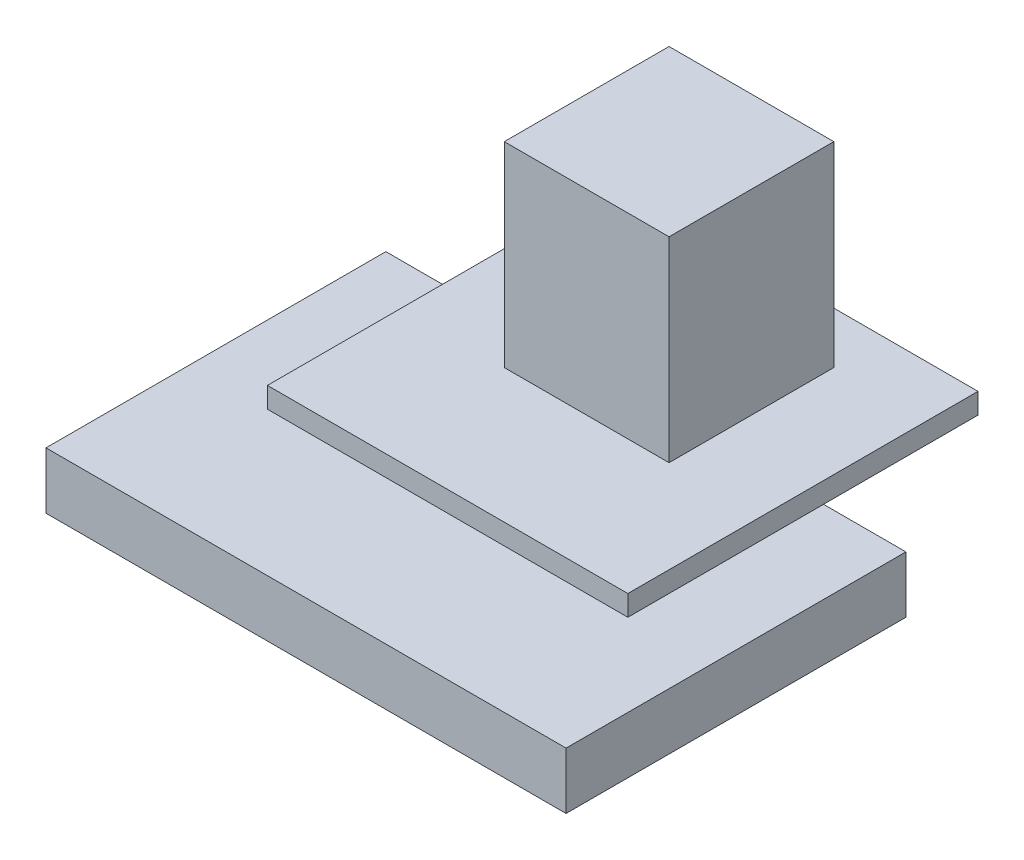
from build123d import *

# Parameters (mm, degrees)
SKETCH1_W           = 50.5
SKETCH1_H           = 33
BOSS_EXTRUDE1_DEPTH = 5.5
SKETCH2_W           = 35
SKETCH2_H           = 34
BOSS_EXTRUDE2_DEPTH = 2
SKETCH3_W           = 16
SKETCH3_H           = 16
BOSS_EXTRUDE3_DEPTH = 19


with BuildPart() as part:
    # Sketch1 → Boss-Extrude1 (new body)
    with BuildSketch(Plane(origin=(0, 0, 0), x_dir=(1, 0, 0), z_dir=(0, 1, 0))):
        with Locations((25.25, 16.5)):
            Rectangle(SKETCH1_W, SKETCH1_H)
    extrude(amount=BOSS_EXTRUDE1_DEPTH)

    # Sketch2 → Boss-Extrude2 (add)
    with BuildSketch(Plane(origin=(0, 5.5, 0), x_dir=(1, 0, 0), z_dir=(0, 1, 0))):
        with Locations((25, 31)):
            Rectangle(SKETCH2_W, SKETCH2_H)
    extrude(amount=BOSS_EXTRUDE2_DEPTH)

    # Sketch3 → Boss-Extrude3 (add)
    with BuildSketch(Plane(origin=(0, 7.5, 0), x_dir=(1, 0, 0), z_dir=(0, 1, 0))):
        with Locations((25.5, 35)):
            Rectangle(SKETCH3_W, SKETCH3_H)
    extrude(amount=BOSS_EXTRUDE3_DEPTH)


solid = part.part
